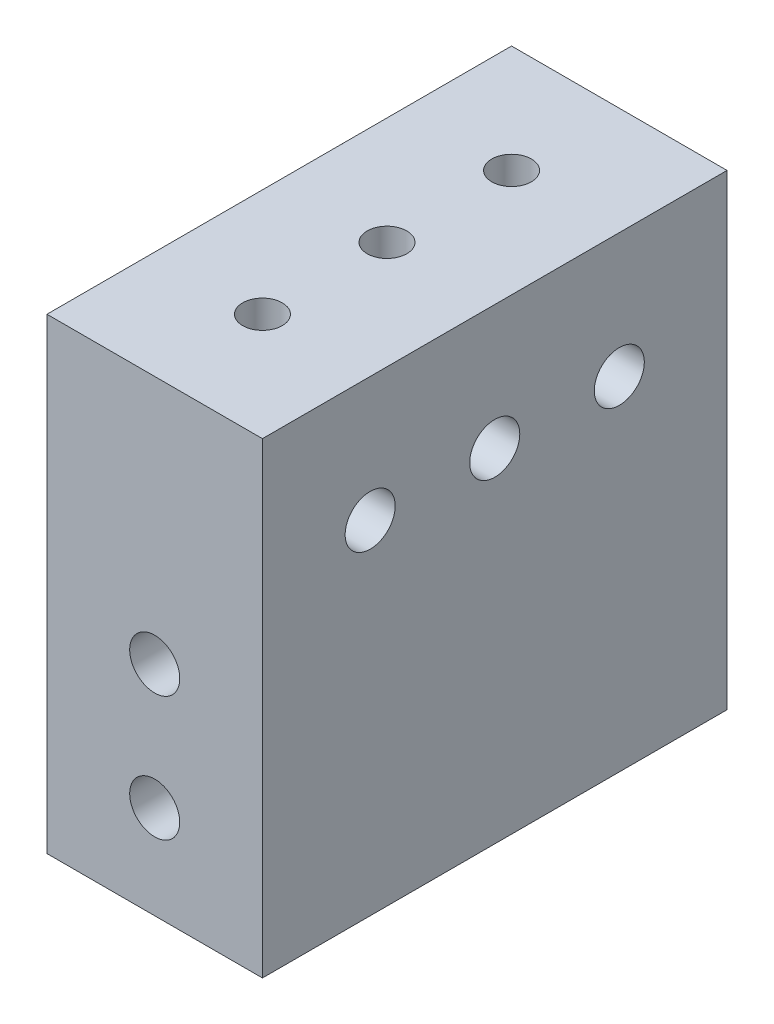
from build123d import *

# Parameters (mm, degrees)
SKETCH1_W              = 21.971
SKETCH1_H              = 47.371
BOSS_EXTRUDE1_DEPTH    = 23.8125
SKETCH2_R              = 2.5527
CUT_EXTRUDE1_DEPTH     = 22.971
SKETCH5_R              = 2.5527
CUT_EXTRUDE2_DEPTH     = 48.371
F_10_32_TAPPED_HOLE1_D = 4.0386


with BuildPart() as part:
    # Sketch1 → Boss-Extrude1 (new body, symmetric)
    with BuildSketch(Plane(origin=(0, 0, 0), x_dir=(1, 0, 0), z_dir=(0, 1, 0))):
        Rectangle(SKETCH1_W, SKETCH1_H)
    extrude(amount=BOSS_EXTRUDE1_DEPTH, both=True)

    # Sketch2 → Cut-Extrude1 (cut, through all)
    with BuildSketch(Plane(origin=(10.9855, 0, 0), x_dir=(0, 0, -1), z_dir=(1, 0, 0))):
        with Locations((-12.7, 11.1125)):
            Circle(SKETCH2_R)
        with Locations((0, 11.1125)):
            Circle(SKETCH2_R)
        with Locations((12.7, 11.1125)):
            Circle(SKETCH2_R)
    extrude(amount=-CUT_EXTRUDE1_DEPTH, mode=Mode.SUBTRACT)

    # Sketch5 → Cut-Extrude2 (cut, through all)
    with BuildSketch(Plane(origin=(0, 0, -23.6855), x_dir=(-1, 0, 0), z_dir=(0, 0, -1))):
        with Locations((0, -1.5875)):
            Circle(SKETCH5_R)
        with Locations((0, -14.2875)):
            Circle(SKETCH5_R)
    extrude(amount=-CUT_EXTRUDE2_DEPTH, mode=Mode.SUBTRACT)

    # #10-32 Tapped Hole1 (through all)
    with Locations(Plane(origin=(0, 23.8125, 12.7), x_dir=(0, 0, 1), z_dir=(0, 1, 0))):
        with Locations((0, 0), (-25.4, 0), (-12.7, 0)):
            Hole(F_10_32_TAPPED_HOLE1_D / 2)


solid = part.part
